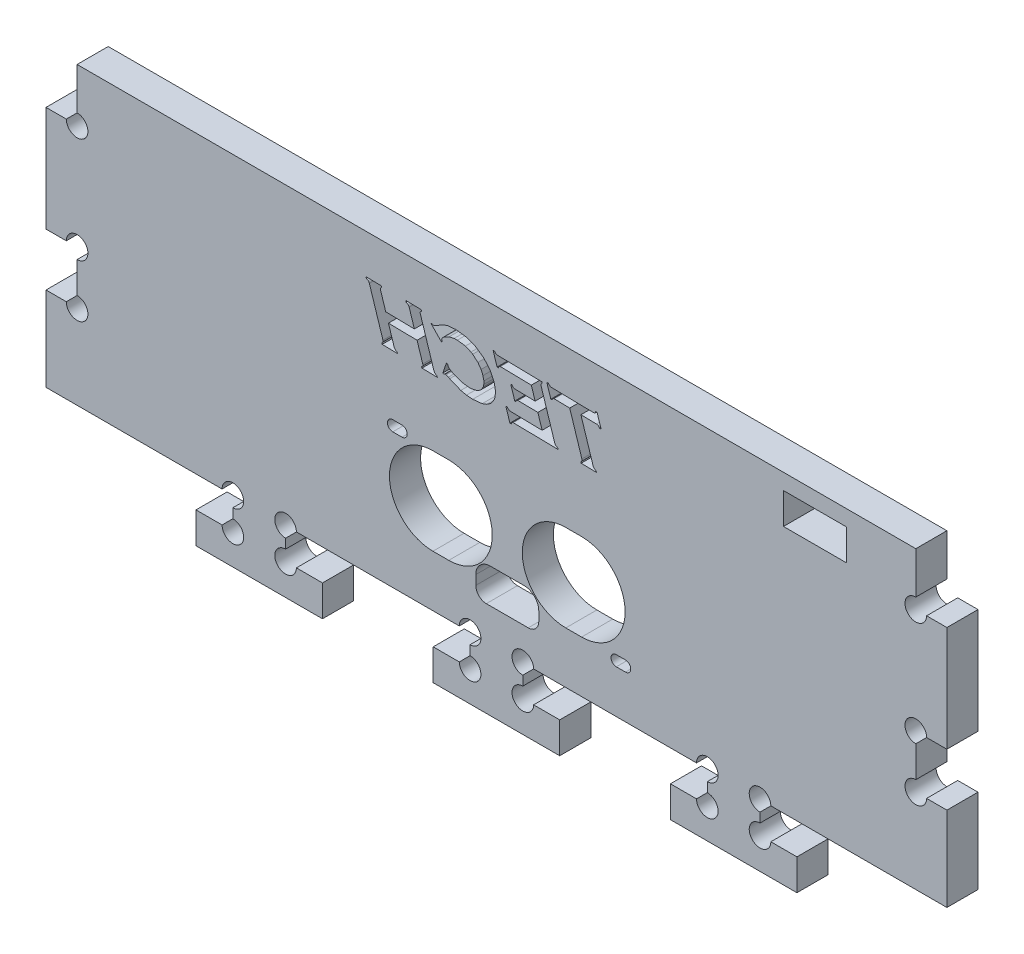
from build123d import *

# Parameters (mm, degrees)
SKETCH1_W           = 170.9
SKETCH1_H           = 70
BOSS_EXTRUDE1_DEPTH = 5.9
CUT_EXTRUDE1_DEPTH  = 6.9
SKETCH3_W           = 5.9
SKETCH3_H           = 10
CUT_EXTRUDE2_DEPTH  = 6.9
CUT_EXTRUDE5_REACH  = 7.9
CUT_EXTRUDE6_REACH  = 7.9
SKETCH5_R           = 2.05
CUT_EXTRUDE7_REACH  = 7.9
SKETCH6_W           = 12
SKETCH6_H           = 5.9
CUT_EXTRUDE9_REACH  = 7.9


with BuildPart() as part:
    # Sketch1 → Boss-Extrude1 (new body)
    with BuildSketch(Plane.XY):
        Rectangle(SKETCH1_W, SKETCH1_H)
    extrude(amount=BOSS_EXTRUDE1_DEPTH)

    # Sketch2 → Cut-Extrude1 (cut, through all)
    with BuildSketch(Plane.XY.offset(5.9)):
        Polygon((-50, -21), (-85.45, -21), (-85.45, -35), (85.45, -35), (85.45, -21), (50, -21), (50, -26.9), (57, -26.9), (57, -32.8), (33, -32.8), (33, -26.9), (40, -26.9), (40, -21), (5, -21), (5, -26.9), (12, -26.9), (12, -32.8), (-12, -32.8), (-12, -26.9), (-5, -26.9), (-5, -21), (-40, -21), (-40, -26.9), (-33, -26.9), (-33, -32.8), (-57, -32.8), (-57, -26.9), (-50, -26.9), align=None)
    extrude(amount=-CUT_EXTRUDE1_DEPTH, mode=Mode.SUBTRACT)

    # Sketch3 → Cut-Extrude2 (cut, through all)
    with BuildSketch(Plane.XY.offset(5.9)):
        with Locations((82.5, 30)):
            Rectangle(SKETCH3_W, SKETCH3_H)
        with Locations((-82.5, 0)):
            Rectangle(SKETCH3_W, SKETCH3_H)
        with Locations((-82.5, 30)):
            Rectangle(SKETCH3_W, SKETCH3_H)
        with Locations((82.5, 0)):
            Rectangle(SKETCH3_W, SKETCH3_H)
    extrude(amount=-CUT_EXTRUDE2_DEPTH, mode=Mode.SUBTRACT)

    # Sketch4 → Cut-Extrude5 (cut, up to next)
    with BuildSketch(Plane.XY, mode=Mode.PRIVATE) as cut_extrude5_sk1:
        with BuildLine():
            Line((-9.228364998, 20.789850245), (-9.247811303, 20.880851706))
            Line((-9.247811303, 20.880851706), (-9.481405057, 21.017407611))
            Line((-9.481405057, 21.017407611), (-10.168538922, 19.007034316))
            Line((-10.168538922, 19.007034316), (-9.947144522, 18.883111212))
            ThreePointArc((-9.947144522, 18.883111212), (-9.829810792, 18.992984326), (-9.681267301, 19.054418329))
            Line((-9.681267301, 19.054418329), (-9.529415034, 19.013484809))
            Line((-9.529415034, 19.013484809), (-9.124867838, 18.84058991))
            Line((-9.124867838, 18.84058991), (-8.867440999, 18.717296569))
            Line((-8.867440999, 18.717296569), (-6.758837234, 17.845584989))
            Line((-6.758837234, 17.845584989), (-5.69104249, 17.608513681))
            Line((-5.69104249, 17.608513681), (-4.504179136, 17.517138188))
            Line((-4.504179136, 17.517138188), (-2.707024252, 17.697210808))
            Line((-2.707024252, 17.697210808), (-1.830689265, 18.024121977))
            Line((-1.830689265, 18.024121977), (-1.120892298, 18.519980757))
            Line((-1.120892298, 18.519980757), (-0.667528987, 19.054008268))
            Line((-0.667528987, 19.054008268), (-0.385098166, 19.620944379))
            Line((-0.385098166, 19.620944379), (-0.264319112, 20.03888197))
            Line((-0.264319112, 20.03888197), (-0.183333617, 20.984793029))
            Line((-0.183333617, 20.984793029), (-0.375528347, 22.130800535))
            Line((-0.375528347, 22.130800535), (-0.441289907, 22.352065033))
            Line((-0.441289907, 22.352065033), (-1.235151059, 24.005895196))
            Line((-1.235151059, 24.005895196), (-2.423299153, 25.375707525))
            Line((-2.423299153, 25.375707525), (-4.017576267, 26.492898775))
            Line((-4.017576267, 26.492898775), (-5.673627283, 27.12019195))
            Line((-5.673627283, 27.12019195), (-7.670967586, 27.37582446))
            Line((-7.670967586, 27.37582446), (-9.143262227, 27.269044948))
            Line((-9.143262227, 27.269044948), (-10.029297894, 26.984147466))
            Line((-10.029297894, 26.984147466), (-11.283977504, 26.256933072))
            Line((-11.283977504, 26.256933072), (-11.572420181, 26.072457983))
            Line((-11.572420181, 26.072457983), (-11.780931815, 25.962228869))
            Line((-11.780931815, 25.962228869), (-11.885728513, 25.936240399))
            Line((-11.885728513, 25.936240399), (-12.004436872, 25.966130154))
            Line((-12.004436872, 25.966130154), (-12.188816724, 26.070577935))
            Line((-12.188816724, 26.070577935), (-12.267448303, 26.125061294))
            Line((-12.267448303, 26.125061294), (-12.410367202, 26.001287373))
            Line((-12.410367202, 26.001287373), (-10.429571956, 23.975394853))
            Line((-10.429571956, 23.975394853), (-10.280408898, 24.101129759))
            Line((-10.280408898, 24.101129759), (-10.355684842, 24.294951541))
            Line((-10.355684842, 24.294951541), (-10.379821545, 24.438872464))
            Line((-10.379821545, 24.438872464), (-10.369777995, 24.536020719))
            Line((-10.369777995, 24.536020719), (-10.337829576, 24.62452244))
            Line((-10.337829576, 24.62452244), (-10.269421347, 24.730605745))
            Line((-10.269421347, 24.730605745), (-10.108576131, 24.894067753))
            Line((-10.108576131, 24.894067753), (-9.819797481, 25.111518306))
            Line((-9.819797481, 25.111518306), (-8.978079092, 25.541742757))
            Line((-8.978079092, 25.541742757), (-8.016003125, 25.757313705))
            Line((-8.016003125, 25.757313705), (-7.408999713, 25.781509668))
            Line((-7.408999713, 25.781509668), (-5.904649259, 25.564154116))
            Line((-5.904649259, 25.564154116), (-4.840789583, 25.114616606))
            Line((-4.840789583, 25.114616606), (-4.517869099, 24.915473965))
            Line((-4.517869099, 24.915473965), (-3.530638956, 24.070739893))
            Line((-3.530638956, 24.070739893), (-2.916615866, 23.215258641))
            Line((-2.916615866, 23.215258641), (-2.558303351, 22.384877687))
            Line((-2.558303351, 22.384877687), (-2.387274391, 21.594589326))
            Line((-2.387274391, 21.594589326), (-2.393881076, 21.023378279))
            Line((-2.393881076, 21.023378279), (-2.506124433, 20.551675161))
            Line((-2.506124433, 20.551675161), (-2.711004085, 20.149325031))
            Line((-2.711004085, 20.149325031), (-2.908128005, 19.894591967))
            Line((-2.908128005, 19.894591967), (-3.310592001, 19.554311678))
            Line((-3.310592001, 19.554311678), (-3.829284817, 19.31023505))
            Line((-3.829284817, 19.31023505), (-4.618580442, 19.145725027))
            Line((-4.618580442, 19.145725027), (-5.273136838, 19.12030252))
            Line((-5.273136838, 19.12030252), (-6.732876232, 19.332889817))
            Line((-6.732876232, 19.332889817), (-8.139388703, 19.869985266))
            Line((-8.139388703, 19.869985266), (-8.751470437, 20.204999797))
            Line((-8.751470437, 20.204999797), (-8.968446544, 20.366326397))
            Line((-8.968446544, 20.366326397), (-9.114966087, 20.523523772))
            Line((-9.114966087, 20.523523772), (-9.203394949, 20.697918464))
            Line((-9.203394949, 20.697918464), (-9.228364998, 20.789850245))
        make_face()
    cut_extrude5_tool1 = extrude(cut_extrude5_sk1.sketch, amount=CUT_EXTRUDE5_REACH, mode=Mode.PRIVATE) & part.part
    add(cut_extrude5_tool1.solids().sort_by_distance((-9.391685, 20.802528, 0))[0], mode=Mode.SUBTRACT)
    # Sketch4 → Cut-Extrude5 (cut, up to next)
    with BuildSketch(Plane.XY, mode=Mode.PRIVATE) as cut_extrude5_sk2:
        with BuildLine():
            Line((-15.058366486, 21.940674548), (-13.978705262, 18.570536672))
            ThreePointArc((-13.978705262, 18.570536672), (-13.976445354, 18.266857366), (-14.219023674, 18.084149986))
            Line((-14.219023674, 18.084149986), (-14.132595873, 17.817684362))
            Line((-14.132595873, 17.817684362), (-11.218956369, 17.766826595))
            Line((-11.218956369, 17.766826595), (-11.30538417, 18.033292219))
            ThreePointArc((-11.30538417, 18.033292219), (-11.650406756, 18.211615167), (-11.860471814, 18.538283701))
            Line((-11.860471814, 18.538283701), (-14.44509261, 26.597767329))
            ThreePointArc((-14.44509261, 26.597767329), (-14.450125471, 26.903988352), (-14.208759466, 27.09250651))
            Line((-14.208759466, 27.09250651), (-14.293117921, 27.358936013))
            Line((-14.293117921, 27.358936013), (-17.206757425, 27.40979378))
            Line((-17.206757425, 27.40979378), (-17.12239897, 27.143364277))
            ThreePointArc((-17.12239897, 27.143364277), (-16.769300958, 26.966682526), (-16.562106054, 26.630579983))
            Line((-16.562106054, 26.630579983), (-15.570725254, 23.539359929))
            Line((-15.570725254, 23.539359929), (-21.000689785, 23.634140312))
            Line((-21.000689785, 23.634140312), (-21.992070585, 26.725360367))
            ThreePointArc((-21.992070585, 26.725360367), (-21.978231036, 27.023349946), (-21.757734546, 27.22427436))
            Line((-21.757734546, 27.22427436), (-21.842093, 27.490703863))
            Line((-21.842093, 27.490703863), (-24.755732505, 27.54156163))
            Line((-24.755732505, 27.54156163), (-24.67137405, 27.275132127))
            ThreePointArc((-24.67137405, 27.275132127), (-24.321363418, 27.098612731), (-24.113078239, 26.766522646))
            Line((-24.113078239, 26.766522646), (-21.529605205, 18.710618028))
            ThreePointArc((-21.529605205, 18.710618028), (-21.546350092, 18.413891725), (-21.768007696, 18.215914968))
            Line((-21.768007696, 18.215914968), (-21.681579895, 17.949449344))
            Line((-21.681579895, 17.949449344), (-18.767940391, 17.898591577))
            Line((-18.767940391, 17.898591577), (-18.854368192, 18.165057201))
            ThreePointArc((-18.854368192, 18.165057201), (-19.197150641, 18.342465466), (-19.408669793, 18.665317056))
            Line((-19.408669793, 18.665317056), (-20.488331017, 22.035454931))
            Line((-20.488331017, 22.035454931), (-15.058366486, 21.940674548))
        make_face()
    cut_extrude5_tool2 = extrude(cut_extrude5_sk2.sketch, amount=CUT_EXTRUDE5_REACH, mode=Mode.PRIVATE) & part.part
    add(cut_extrude5_tool2.solids().sort_by_distance((-17.996255, 22.676724, 0))[0], mode=Mode.SUBTRACT)
    # Sketch4 → Cut-Extrude5 (cut, up to next)
    with BuildSketch(Plane.XY, mode=Mode.PRIVATE) as cut_extrude5_sk3:
        with BuildLine():
            Line((11.048220995, 18.148179886), (8.468669931, 26.191596186))
            ThreePointArc((8.468669931, 26.191596186), (8.462188147, 26.499942683), (8.703042091, 26.692579526))
            Line((8.703042091, 26.692579526), (8.618683636, 26.959009029))
            Line((8.618683636, 26.959009029), (0.241970061, 27.105225109))
            ThreePointArc((0.241970061, 27.105225109), (-0.119814168, 27.233450331), (-0.382245392, 27.513556361))
            Line((-0.382245392, 27.513556361), (-0.647121711, 27.518179795))
            Line((-0.647121711, 27.518179795), (0.120381769, 25.120169783))
            Line((0.120381769, 25.120169783), (0.385258087, 25.11554635))
            ThreePointArc((0.385258087, 25.11554635), (0.487773924, 25.387069577), (0.752259483, 25.506575848))
            Line((0.752259483, 25.506575848), (6.614717378, 25.404246265))
            Line((6.614717378, 25.404246265), (7.341076303, 23.139432945))
            Line((7.341076303, 23.139432945), (3.591420918, 23.204883423))
            ThreePointArc((3.591420918, 23.204883423), (3.216891685, 23.309795972), (2.973413504, 23.613106314))
            Line((2.973413504, 23.613106314), (2.708537185, 23.617729748))
            Line((2.708537185, 23.617729748), (3.478110011, 21.219683616))
            Line((3.478110011, 21.219683616), (3.742986329, 21.215060183))
            ThreePointArc((3.742986329, 21.215060183), (3.842375704, 21.485351863), (4.103779686, 21.606198042))
            Line((4.103779686, 21.606198042), (7.853435071, 21.540747564))
            Line((7.853435071, 21.540747564), (8.664152451, 19.009504741))
            Line((8.664152451, 19.009504741), (2.667187051, 19.114182162))
            ThreePointArc((2.667187051, 19.114182162), (2.305340003, 19.239623016), (2.04711029, 19.522441173))
            Line((2.04711029, 19.522441173), (1.782233972, 19.527064606))
            Line((1.782233972, 19.527064606), (2.549737451, 17.129054595))
            Line((2.549737451, 17.129054595), (2.81461377, 17.124431162))
            ThreePointArc((2.81461377, 17.124431162), (2.917129607, 17.395954389), (3.181615165, 17.51546066))
            Line((3.181615165, 17.51546066), (11.692836246, 17.366896743))
            Line((11.692836246, 17.366896743), (11.606408444, 17.633362367))
            ThreePointArc((11.606408444, 17.633362367), (11.257451432, 17.815022325), (11.048220995, 18.148179886))
        make_face()
    cut_extrude5_tool3 = extrude(cut_extrude5_sk3.sketch, amount=CUT_EXTRUDE5_REACH, mode=Mode.PRIVATE) & part.part
    add(cut_extrude5_tool3.solids().sort_by_distance((6.223935, 22.23405, 0))[0], mode=Mode.SUBTRACT)
    # Sketch4 → Cut-Extrude5 (cut, up to next)
    with BuildSketch(Plane.XY, mode=Mode.PRIVATE) as cut_extrude5_sk4:
        with BuildLine():
            Line((10.452124403, 26.927006202), (18.446008924, 26.787472428))
            ThreePointArc((18.446008924, 26.787472428), (18.741833389, 26.879049193), (18.821287705, 27.178357444))
            Line((18.821287705, 27.178357444), (19.086164023, 27.173734011))
            Line((19.086164023, 27.173734011), (19.853667503, 24.775724))
            Line((19.853667503, 24.775724), (19.588791184, 24.780347433))
            ThreePointArc((19.588791184, 24.780347433), (19.331520606, 25.072103357), (18.960437039, 25.188750927))
            Line((18.960437039, 25.188750927), (16.017826687, 25.240114382))
            Line((16.017826687, 25.240114382), (18.33028653, 18.023140936))
            ThreePointArc((18.33028653, 18.023140936), (18.540657239, 17.689098393), (18.890507205, 17.50621795))
            Line((18.890507205, 17.50621795), (18.976935006, 17.239752327))
            Line((18.976935006, 17.239752327), (16.063295502, 17.290610093))
            Line((16.063295502, 17.290610093), (15.976867701, 17.557075717))
            ThreePointArc((15.976867701, 17.557075717), (16.229611984, 17.745444199), (16.211275981, 18.060128403))
            Line((16.211275981, 18.060128403), (13.898816138, 25.277101848))
            Line((13.898816138, 25.277101848), (10.962413825, 25.328356941))
            ThreePointArc((10.962413825, 25.328356941), (10.691765113, 25.211530486), (10.582996352, 24.937544167))
            Line((10.582996352, 24.937544167), (10.318120034, 24.9421676))
            Line((10.318120034, 24.9421676), (9.550616554, 27.340177611))
            Line((9.550616554, 27.340177611), (9.815492873, 27.335554178))
            ThreePointArc((9.815492873, 27.335554178), (10.095066147, 27.070908598), (10.452124403, 26.927006202))
        make_face()
    cut_extrude5_tool4 = extrude(cut_extrude5_sk4.sketch, amount=CUT_EXTRUDE5_REACH, mode=Mode.PRIVATE) & part.part
    add(cut_extrude5_tool4.solids().sort_by_distance((15.508875, 23.527037, 0))[0], mode=Mode.SUBTRACT)

    # Sketch5 → Cut-Extrude6 (cut, up to next)
    with BuildSketch(Plane.XY.offset(5.9), mode=Mode.PRIVATE) as cut_extrude6_sk1:
        with Locations((-50, -26.9)):
            Circle(SKETCH5_R)
    cut_extrude6_tool1 = extrude(cut_extrude6_sk1.sketch, amount=-CUT_EXTRUDE6_REACH, mode=Mode.PRIVATE) & part.part
    add(cut_extrude6_tool1.solids().sort_by_distance((-50, -26.9, 5.9))[0], mode=Mode.SUBTRACT)
    # Sketch5 → Cut-Extrude6 (cut, up to next)
    with BuildSketch(Plane.XY.offset(5.9), mode=Mode.PRIVATE) as cut_extrude6_sk2:
        with Locations((-40, -26.9)):
            Circle(SKETCH5_R)
    cut_extrude6_tool2 = extrude(cut_extrude6_sk2.sketch, amount=-CUT_EXTRUDE6_REACH, mode=Mode.PRIVATE) & part.part
    add(cut_extrude6_tool2.solids().sort_by_distance((-40, -26.9, 5.9))[0], mode=Mode.SUBTRACT)
    # Sketch5 → Cut-Extrude6 (cut, up to next)
    with BuildSketch(Plane.XY.offset(5.9), mode=Mode.PRIVATE) as cut_extrude6_sk3:
        with Locations((-5, -26.9)):
            Circle(SKETCH5_R)
    cut_extrude6_tool3 = extrude(cut_extrude6_sk3.sketch, amount=-CUT_EXTRUDE6_REACH, mode=Mode.PRIVATE) & part.part
    add(cut_extrude6_tool3.solids().sort_by_distance((-5, -26.9, 5.9))[0], mode=Mode.SUBTRACT)
    # Sketch5 → Cut-Extrude6 (cut, up to next)
    with BuildSketch(Plane.XY.offset(5.9), mode=Mode.PRIVATE) as cut_extrude6_sk4:
        with Locations((5, -26.9)):
            Circle(SKETCH5_R)
    cut_extrude6_tool4 = extrude(cut_extrude6_sk4.sketch, amount=-CUT_EXTRUDE6_REACH, mode=Mode.PRIVATE) & part.part
    add(cut_extrude6_tool4.solids().sort_by_distance((5, -26.9, 5.9))[0], mode=Mode.SUBTRACT)
    # Sketch5 → Cut-Extrude6 (cut, up to next)
    with BuildSketch(Plane.XY.offset(5.9), mode=Mode.PRIVATE) as cut_extrude6_sk5:
        with Locations((40, -26.9)):
            Circle(SKETCH5_R)
    cut_extrude6_tool5 = extrude(cut_extrude6_sk5.sketch, amount=-CUT_EXTRUDE6_REACH, mode=Mode.PRIVATE) & part.part
    add(cut_extrude6_tool5.solids().sort_by_distance((40, -26.9, 5.9))[0], mode=Mode.SUBTRACT)
    # Sketch5 → Cut-Extrude6 (cut, up to next)
    with BuildSketch(Plane.XY.offset(5.9), mode=Mode.PRIVATE) as cut_extrude6_sk6:
        with Locations((50, -26.9)):
            Circle(SKETCH5_R)
    cut_extrude6_tool6 = extrude(cut_extrude6_sk6.sketch, amount=-CUT_EXTRUDE6_REACH, mode=Mode.PRIVATE) & part.part
    add(cut_extrude6_tool6.solids().sort_by_distance((50, -26.9, 5.9))[0], mode=Mode.SUBTRACT)
    # Sketch5 → Cut-Extrude6 (cut, up to next)
    with BuildSketch(Plane.XY.offset(5.9), mode=Mode.PRIVATE) as cut_extrude6_sk7:
        with Locations((50, -21)):
            Circle(SKETCH5_R)
    cut_extrude6_tool7 = extrude(cut_extrude6_sk7.sketch, amount=-CUT_EXTRUDE6_REACH, mode=Mode.PRIVATE) & part.part
    add(cut_extrude6_tool7.solids().sort_by_distance((50, -21, 5.9))[0], mode=Mode.SUBTRACT)
    # Sketch5 → Cut-Extrude6 (cut, up to next)
    with BuildSketch(Plane.XY.offset(5.9), mode=Mode.PRIVATE) as cut_extrude6_sk8:
        with Locations((40, -21)):
            Circle(SKETCH5_R)
    cut_extrude6_tool8 = extrude(cut_extrude6_sk8.sketch, amount=-CUT_EXTRUDE6_REACH, mode=Mode.PRIVATE) & part.part
    add(cut_extrude6_tool8.solids().sort_by_distance((40, -21, 5.9))[0], mode=Mode.SUBTRACT)
    # Sketch5 → Cut-Extrude6 (cut, up to next)
    with BuildSketch(Plane.XY.offset(5.9), mode=Mode.PRIVATE) as cut_extrude6_sk9:
        with Locations((5, -21)):
            Circle(SKETCH5_R)
    cut_extrude6_tool9 = extrude(cut_extrude6_sk9.sketch, amount=-CUT_EXTRUDE6_REACH, mode=Mode.PRIVATE) & part.part
    add(cut_extrude6_tool9.solids().sort_by_distance((5, -21, 5.9))[0], mode=Mode.SUBTRACT)
    # Sketch5 → Cut-Extrude6 (cut, up to next)
    with BuildSketch(Plane.XY.offset(5.9), mode=Mode.PRIVATE) as cut_extrude6_sk10:
        with Locations((-5, -21)):
            Circle(SKETCH5_R)
    cut_extrude6_tool10 = extrude(cut_extrude6_sk10.sketch, amount=-CUT_EXTRUDE6_REACH, mode=Mode.PRIVATE) & part.part
    add(cut_extrude6_tool10.solids().sort_by_distance((-5, -21, 5.9))[0], mode=Mode.SUBTRACT)
    # Sketch5 → Cut-Extrude6 (cut, up to next)
    with BuildSketch(Plane.XY.offset(5.9), mode=Mode.PRIVATE) as cut_extrude6_sk11:
        with Locations((-40, -21)):
            Circle(SKETCH5_R)
    cut_extrude6_tool11 = extrude(cut_extrude6_sk11.sketch, amount=-CUT_EXTRUDE6_REACH, mode=Mode.PRIVATE) & part.part
    add(cut_extrude6_tool11.solids().sort_by_distance((-40, -21, 5.9))[0], mode=Mode.SUBTRACT)
    # Sketch5 → Cut-Extrude6 (cut, up to next)
    with BuildSketch(Plane.XY.offset(5.9), mode=Mode.PRIVATE) as cut_extrude6_sk12:
        with Locations((-50, -21)):
            Circle(SKETCH5_R)
    cut_extrude6_tool12 = extrude(cut_extrude6_sk12.sketch, amount=-CUT_EXTRUDE6_REACH, mode=Mode.PRIVATE) & part.part
    add(cut_extrude6_tool12.solids().sort_by_distance((-50, -21, 5.9))[0], mode=Mode.SUBTRACT)
    # Sketch5 → Cut-Extrude6 (cut, up to next)
    with BuildSketch(Plane.XY.offset(5.9), mode=Mode.PRIVATE) as cut_extrude6_sk13:
        with Locations((-79.55, -5)):
            Circle(SKETCH5_R)
    cut_extrude6_tool13 = extrude(cut_extrude6_sk13.sketch, amount=-CUT_EXTRUDE6_REACH, mode=Mode.PRIVATE) & part.part
    add(cut_extrude6_tool13.solids().sort_by_distance((-79.55, -5, 5.9))[0], mode=Mode.SUBTRACT)
    # Sketch5 → Cut-Extrude6 (cut, up to next)
    with BuildSketch(Plane.XY.offset(5.9), mode=Mode.PRIVATE) as cut_extrude6_sk14:
        with Locations((-79.55, 5)):
            Circle(SKETCH5_R)
    cut_extrude6_tool14 = extrude(cut_extrude6_sk14.sketch, amount=-CUT_EXTRUDE6_REACH, mode=Mode.PRIVATE) & part.part
    add(cut_extrude6_tool14.solids().sort_by_distance((-79.55, 5, 5.9))[0], mode=Mode.SUBTRACT)
    # Sketch5 → Cut-Extrude6 (cut, up to next)
    with BuildSketch(Plane.XY.offset(5.9), mode=Mode.PRIVATE) as cut_extrude6_sk15:
        with Locations((-79.55, 25)):
            Circle(SKETCH5_R)
    cut_extrude6_tool15 = extrude(cut_extrude6_sk15.sketch, amount=-CUT_EXTRUDE6_REACH, mode=Mode.PRIVATE) & part.part
    add(cut_extrude6_tool15.solids().sort_by_distance((-79.55, 25, 5.9))[0], mode=Mode.SUBTRACT)
    # Sketch5 → Cut-Extrude6 (cut, up to next)
    with BuildSketch(Plane.XY.offset(5.9), mode=Mode.PRIVATE) as cut_extrude6_sk16:
        with Locations((79.55, 25)):
            Circle(SKETCH5_R)
    cut_extrude6_tool16 = extrude(cut_extrude6_sk16.sketch, amount=-CUT_EXTRUDE6_REACH, mode=Mode.PRIVATE) & part.part
    add(cut_extrude6_tool16.solids().sort_by_distance((79.55, 25, 5.9))[0], mode=Mode.SUBTRACT)
    # Sketch5 → Cut-Extrude6 (cut, up to next)
    with BuildSketch(Plane.XY.offset(5.9), mode=Mode.PRIVATE) as cut_extrude6_sk17:
        with Locations((79.55, 5)):
            Circle(SKETCH5_R)
    cut_extrude6_tool17 = extrude(cut_extrude6_sk17.sketch, amount=-CUT_EXTRUDE6_REACH, mode=Mode.PRIVATE) & part.part
    add(cut_extrude6_tool17.solids().sort_by_distance((79.55, 5, 5.9))[0], mode=Mode.SUBTRACT)
    # Sketch5 → Cut-Extrude6 (cut, up to next)
    with BuildSketch(Plane.XY.offset(5.9), mode=Mode.PRIVATE) as cut_extrude6_sk18:
        with Locations((79.55, -5)):
            Circle(SKETCH5_R)
    cut_extrude6_tool18 = extrude(cut_extrude6_sk18.sketch, amount=-CUT_EXTRUDE6_REACH, mode=Mode.PRIVATE) & part.part
    add(cut_extrude6_tool18.solids().sort_by_distance((79.55, -5, 5.9))[0], mode=Mode.SUBTRACT)

    # Sketch6 → Cut-Extrude7 (cut, up to next)
    with BuildSketch(Plane(origin=(0, 0, 0), x_dir=(-1, 0, 0), z_dir=(0, 0, -1)), mode=Mode.PRIVATE) as cut_extrude7_sk1:
        with Locations((-60.45, 29.05)):
            Rectangle(SKETCH6_W, SKETCH6_H)
    cut_extrude7_tool1 = extrude(cut_extrude7_sk1.sketch, amount=-CUT_EXTRUDE7_REACH, mode=Mode.PRIVATE) & part.part
    add(cut_extrude7_tool1.solids().sort_by_distance((60.45, 29.05, 0))[0], mode=Mode.SUBTRACT)

    # Sketch8 → Cut-Extrude9 (cut, up to next)
    with BuildSketch(Plane(origin=(0, 0, 0), x_dir=(-1, 0, 0), z_dir=(0, 0, -1)), mode=Mode.PRIVATE) as cut_extrude9_sk1:
        with BuildLine():
            Line((-8.028160456, -12.765265314), (-8.028160456, -10.990265314))
            ThreePointArc((-8.028160456, -10.990265314), (-7.215381774, -9.028043996), (-5.253160456, -8.215265314))
            Line((-5.253160456, -8.215265314), (1.146839544, -8.215265314))
            ThreePointArc((1.146839544, -8.215265314), (3.109060862, -9.028043996), (3.921839544, -10.990265314))
            Line((3.921839544, -10.990265314), (3.921839544, -12.765265314))
            ThreePointArc((3.921839544, -12.765265314), (3.336053106, -14.179478876), (1.921839544, -14.765265314))
            Line((1.921839544, -14.765265314), (-6.028160456, -14.765265314))
            ThreePointArc((-6.028160456, -14.765265314), (-7.442374019, -14.179478876), (-8.028160456, -12.765265314))
        make_face()
    cut_extrude9_tool1 = extrude(cut_extrude9_sk1.sketch, amount=-CUT_EXTRUDE9_REACH, mode=Mode.PRIVATE) & part.part
    add(cut_extrude9_tool1.solids().sort_by_distance((2.05316, -11.543781, 0))[0], mode=Mode.SUBTRACT)
    # Sketch8 → Cut-Extrude9 (cut, up to next)
    with BuildSketch(Plane(origin=(0, 0, 0), x_dir=(-1, 0, 0), z_dir=(0, 0, -1)), mode=Mode.PRIVATE) as cut_extrude9_sk2:
        with BuildLine():
            Line((12.046839544, 5.284734686), (9.046839544, 5.284734686))
            ThreePointArc((9.046839544, 5.284734686), (0.796839544, -2.965265314), (9.046839544, -11.215265314))
            Line((9.046839544, -11.215265314), (12.046839544, -11.215265314))
            ThreePointArc((12.046839544, -11.215265314), (20.296839544, -2.965265314), (12.046839544, 5.284734686))
        make_face()
    cut_extrude9_tool2 = extrude(cut_extrude9_sk2.sketch, amount=-CUT_EXTRUDE9_REACH, mode=Mode.PRIVATE) & part.part
    add(cut_extrude9_tool2.solids().sort_by_distance((-10.54684, -2.965265, 0))[0], mode=Mode.SUBTRACT)
    # Sketch8 → Cut-Extrude9 (cut, up to next)
    with BuildSketch(Plane(origin=(0, 0, 0), x_dir=(-1, 0, 0), z_dir=(0, 0, -1)), mode=Mode.PRIVATE) as cut_extrude9_sk3:
        with BuildLine():
            Line((-13.153160456, 5.284734686), (-16.153160456, 5.284734686))
            ThreePointArc((-16.153160456, 5.284734686), (-24.403160456, -2.965265314), (-16.153160456, -11.215265314))
            Line((-16.153160456, -11.215265314), (-13.153160456, -11.215265314))
            ThreePointArc((-13.153160456, -11.215265314), (-4.903160456, -2.965265314), (-13.153160456, 5.284734686))
        make_face()
    cut_extrude9_tool3 = extrude(cut_extrude9_sk3.sketch, amount=-CUT_EXTRUDE9_REACH, mode=Mode.PRIVATE) & part.part
    add(cut_extrude9_tool3.solids().sort_by_distance((14.65316, -2.965265, 0))[0], mode=Mode.SUBTRACT)
    # Sketch8 → Cut-Extrude9 (cut, up to next)
    with BuildSketch(Plane(origin=(0, 0, 0), x_dir=(-1, 0, 0), z_dir=(0, 0, -1)), mode=Mode.PRIVATE) as cut_extrude9_sk4:
        with BuildLine():
            Line((-24.478160456, -12.815265314), (-22.728160456, -12.815265314))
            ThreePointArc((-22.728160456, -12.815265314), (-21.728160456, -11.815265314), (-22.728160456, -10.815265314))
            Line((-22.728160456, -10.815265314), (-24.478160456, -10.815265314))
            ThreePointArc((-24.478160456, -10.815265314), (-25.478160456, -11.815265314), (-24.478160456, -12.815265314))
        make_face()
    cut_extrude9_tool4 = extrude(cut_extrude9_sk4.sketch, amount=-CUT_EXTRUDE9_REACH, mode=Mode.PRIVATE) & part.part
    add(cut_extrude9_tool4.solids().sort_by_distance((23.60316, -11.815265, 0))[0], mode=Mode.SUBTRACT)
    # Sketch8 → Cut-Extrude9 (cut, up to next)
    with BuildSketch(Plane(origin=(0, 0, 0), x_dir=(-1, 0, 0), z_dir=(0, 0, -1)), mode=Mode.PRIVATE) as cut_extrude9_sk5:
        with BuildLine():
            Line((17.921839544, 4.584734686), (19.671839544, 4.584734686))
            ThreePointArc((19.671839544, 4.584734686), (20.671839544, 5.584734686), (19.671839544, 6.584734686))
            Line((19.671839544, 6.584734686), (17.921839544, 6.584734686))
            ThreePointArc((17.921839544, 6.584734686), (16.921839544, 5.584734686), (17.921839544, 4.584734686))
        make_face()
    cut_extrude9_tool5 = extrude(cut_extrude9_sk5.sketch, amount=-CUT_EXTRUDE9_REACH, mode=Mode.PRIVATE) & part.part
    add(cut_extrude9_tool5.solids().sort_by_distance((-18.79684, 5.584735, 0))[0], mode=Mode.SUBTRACT)


solid = part.part
